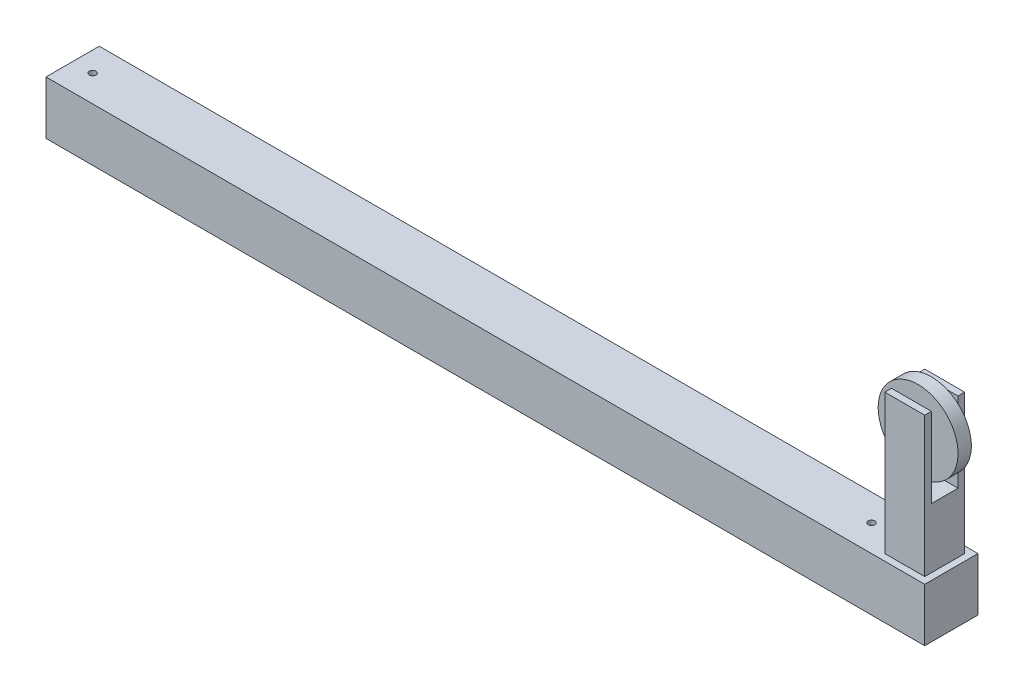
from build123d import *

# Parameters (mm, degrees)
SKETCH1_W                       = 1676.4
SKETCH1_H                       = 101.6
BOSS_EXTRUDE1_DEPTH             = 101.6
SKETCH3_W                       = 76.2
SKETCH3_H                       = 76.2
CUT_EXTRUDE1_DEPTH              = 127
SKETCH5_W                       = 76.2
SKETCH5_H                       = 76.2
BOSS_EXTRUDE2_DEPTH             = 114.3
SKETCH6_W                       = 76.2
SKETCH6_H                       = 12.7
BOSS_EXTRUDE3_DEPTH             = 152.4
BOSS_EXTRUDE4_REACH             = 52.8
SKETCH7_R                       = 12.7
BOSS_EXTRUDE4_DIRECTION_2_REACH = 52.8
SKETCH8_R                       = 76.2
BOSS_EXTRUDE5_DEPTH             = 12.7
BOSS_EXTRUDE5_DEPTH_BACK        = 12.7
SKETCH9_R                       = 6.35
CUT_EXTRUDE2_DEPTH              = 12.7


with BuildPart() as part:
    # Sketch1 → Boss-Extrude1 (new body)
    with BuildSketch(Plane.XY):
        with Locations((838.2, 50.8)):
            Rectangle(SKETCH1_W, SKETCH1_H)
    extrude(amount=BOSS_EXTRUDE1_DEPTH)

    # Sketch3 → Cut-Extrude1 (cut)
    with BuildSketch(Plane.ZY):
        with Locations((50.8, 50.8)):
            Rectangle(SKETCH3_W, SKETCH3_H)
    extrude(amount=-CUT_EXTRUDE1_DEPTH, mode=Mode.SUBTRACT)

    # Sketch5 → Boss-Extrude2 (add)
    with BuildSketch(Plane(origin=(0, 101.6, 0), x_dir=(1, 0, 0), z_dir=(0, 1, 0))):
        with Locations((1625.6, -50.8)):
            Rectangle(SKETCH5_W, SKETCH5_H)
    extrude(amount=BOSS_EXTRUDE2_DEPTH)

    # Sketch6 → Boss-Extrude3 (add)
    with BuildSketch(Plane(origin=(0, 215.9, 0), x_dir=(1, 0, 0), z_dir=(0, 1, 0))):
        with Locations((1625.6, -19.05)):
            Rectangle(SKETCH6_W, SKETCH6_H)
        with Locations((1625.6, -82.55)):
            Rectangle(SKETCH6_W, SKETCH6_H)
    extrude(amount=BOSS_EXTRUDE3_DEPTH)

    # Boss-Extrude4: up to this face of the body (flat: up to its plane)
    boss_extrude4_end = Plane(part.part.faces().sort_by_distance((1625.6, 292.1, 25.4))[0])
    # Sketch7 → Boss-Extrude4 (add, up to the picked face)
    with BuildSketch(Plane(origin=(0, 0, 50.8), x_dir=(-1, 0, 0), z_dir=(0, 0, -1)), mode=Mode.PRIVATE) as boss_extrude4_sk1:
        with Locations((-1625.6, 311.15)):
            Circle(SKETCH7_R)
    boss_extrude4_tool1 = split(extrude(boss_extrude4_sk1.sketch, amount=BOSS_EXTRUDE4_REACH, mode=Mode.PRIVATE), bisect_by=boss_extrude4_end, keep=Keep.BOTH, mode=Mode.PRIVATE)
    add(boss_extrude4_tool1.solids().sort_by_distance((1625.6, 311.15, 50.8))[0])

    # Boss-Extrude4 direction 2: up to this face of the body (flat: up to its plane)
    boss_extrude4_direction_2_end = Plane(part.part.faces().sort_by_distance((1625.6, 292.1, 76.2))[0])
    # Sketch7 → Boss-Extrude4 direction 2 (add, up to the picked face)
    with BuildSketch(Plane(origin=(0, 0, 50.8), x_dir=(-1, 0, 0), z_dir=(0, 0, -1)), mode=Mode.PRIVATE) as boss_extrude4_direction_2_sk1:
        with Locations((-1625.6, 311.15)):
            Circle(SKETCH7_R)
    boss_extrude4_direction_2_tool1 = split(extrude(boss_extrude4_direction_2_sk1.sketch, amount=-BOSS_EXTRUDE4_DIRECTION_2_REACH, mode=Mode.PRIVATE), bisect_by=boss_extrude4_direction_2_end, keep=Keep.BOTH, mode=Mode.PRIVATE)
    add(boss_extrude4_direction_2_tool1.solids().sort_by_distance((1625.6, 311.15, 50.8))[0])

    # Sketch8 → Boss-Extrude5 (add, two sides)
    with BuildSketch(Plane(origin=(0, 0, 50.8), x_dir=(-1, 0, 0), z_dir=(0, 0, -1))) as boss_extrude5_sk:
        with Locations((-1625.6, 311.15)):
            Circle(SKETCH8_R)
    extrude(amount=BOSS_EXTRUDE5_DEPTH)
    extrude(boss_extrude5_sk.sketch, amount=-BOSS_EXTRUDE5_DEPTH_BACK)

    # Sketch9 → Cut-Extrude2 (cut)
    with BuildSketch(Plane(origin=(0, 101.6, 0), x_dir=(1, 0, 0), z_dir=(0, 1, 0))):
        with Locations((38.1, -50.8)):
            Circle(SKETCH9_R)
        with Locations((1524, -50.8)):
            Circle(SKETCH9_R)
    extrude(amount=-CUT_EXTRUDE2_DEPTH, mode=Mode.SUBTRACT)


solid = part.part
